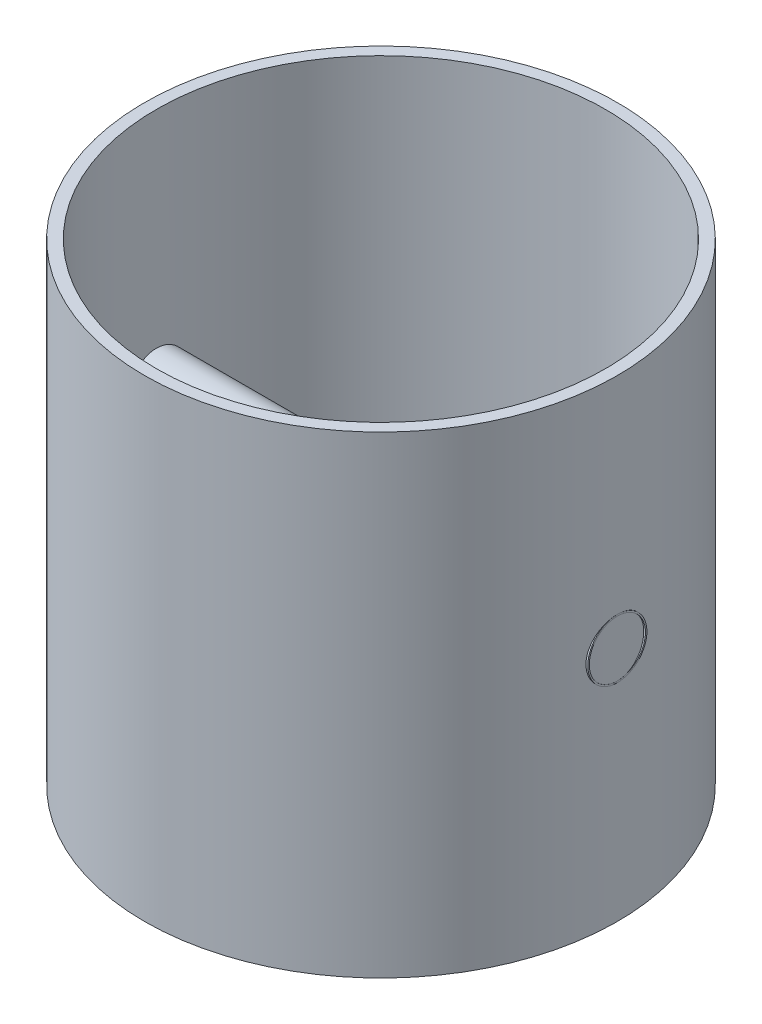
from build123d import *
from build123d.topology import SkipClean

# Parameters (mm, degrees)
SKETCH1_R           = 20
BOSS_EXTRUDE1_DEPTH = 40
SKETCH2_R           = 19
CUT_EXTRUDE1_DEPTH  = 39
BOSS_EXTRUDE2_START = -20
SKETCH5_R           = 2.5
SKETCH5_R_2         = 2.375
BOSS_EXTRUDE2_DEPTH = 40


with BuildPart() as part:
    # Sketch1 → Boss-Extrude1 (new body)
    with BuildSketch(Plane(origin=(0, 0, 0), x_dir=(1, 0, 0), z_dir=(0, 1, 0))):
        with Locations(Location((0, 0, 0), (0, 0, 270))):
            Circle(SKETCH1_R)
    extrude(amount=BOSS_EXTRUDE1_DEPTH)

    # Sketch2 → Cut-Extrude1 (cut)
    with BuildSketch(Plane(origin=(0, 40, 0), x_dir=(1, 0, 0), z_dir=(0, 1, 0))):
        with Locations(Location((0, 0, 0), (0, 0, 270))):
            Circle(SKETCH2_R)
    extrude(amount=-CUT_EXTRUDE1_DEPTH, mode=Mode.SUBTRACT)

    # Sketch5 → Boss-Extrude2 (add)
    with SkipClean():  # the faces are left unmerged after this step: merging them gives an invalid solid
        with BuildSketch(Plane(origin=(0, 0, 0), x_dir=(0, 0, -1), z_dir=(1, 0, 0)).offset(BOSS_EXTRUDE2_START)):
            with Locations(Location((0, 20, 0), (0, 0, 180))):
                Circle(SKETCH5_R)
            with Locations(Location((0, 20, 0), (0, 0, 180))):
                Circle(SKETCH5_R_2, mode=Mode.SUBTRACT)
        extrude(amount=BOSS_EXTRUDE2_DEPTH)


solid = part.part
